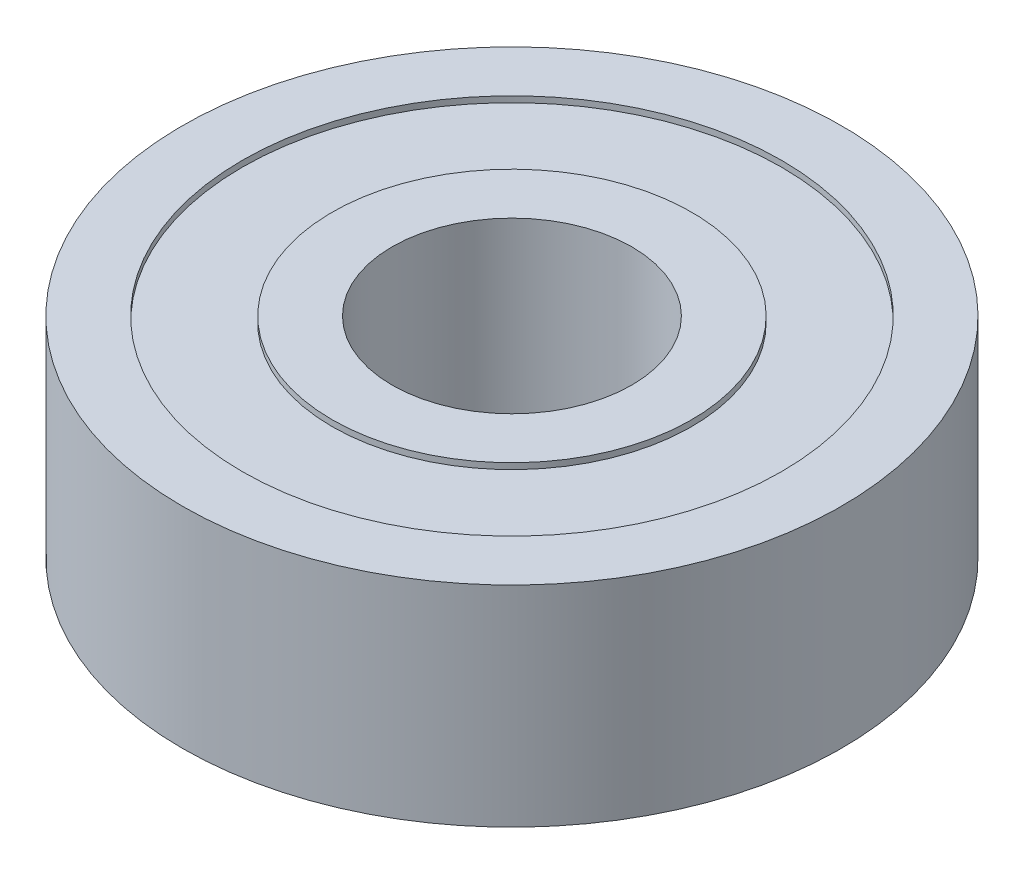
from build123d import *


with BuildPart() as part:
    # 草图1 → 旋转1 (revolve)
    with BuildSketch(Plane.XY):
        Polygon((-4, 0), (-6, 0), (-6, 0.2), (-9, 0.2), (-9, 0), (-11, 0), (-11, 7), (-9, 7), (-9, 6.8), (-6, 6.8), (-6, 7), (-4, 7), align=None)
    revolve(axis=Axis((0, 19.345722395, 0), (0, -1, 0)))


solid = part.part
